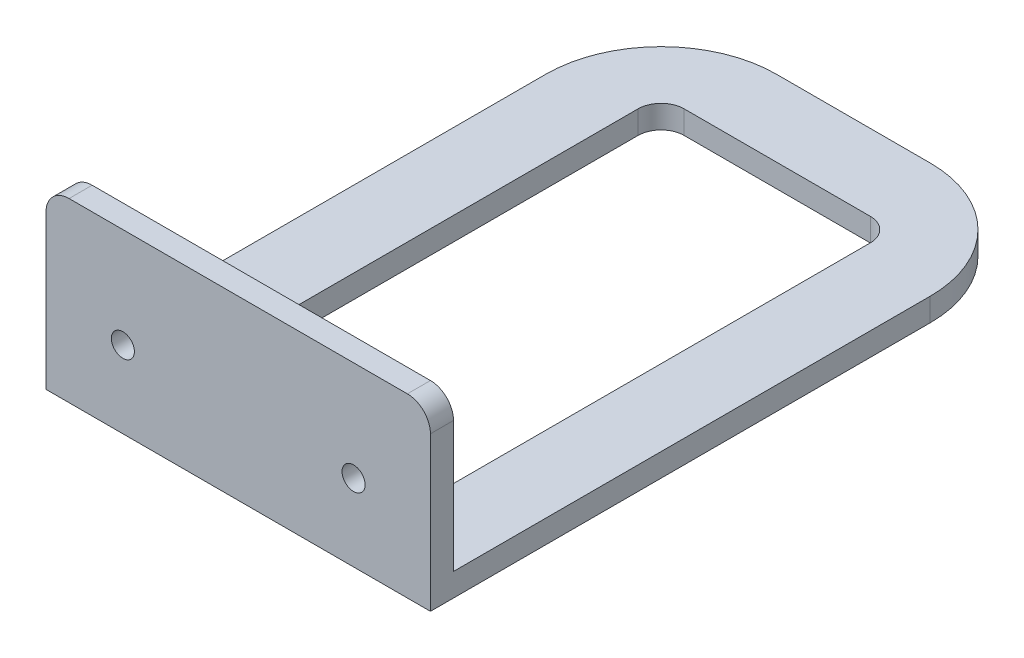
from build123d import *

# Parameters (mm, degrees)
SKETCH1_W           = 50
SKETCH1_H           = 80
BOSS_EXTRUDE1_DEPTH = 3
SKETCH2_W           = 50
SKETCH2_H           = 3
BOSS_EXTRUDE2_DEPTH = 20
FILLET1_R           = 3
FILLET2_R           = 15
CUT_EXTRUDE1_DEPTH  = 4
CUT_EXTRUDE2_DEPTH  = 81


with BuildPart() as part:
    # Sketch1 → Boss-Extrude1 (new body)
    with BuildSketch(Plane(origin=(0, 0, 0), x_dir=(1, 0, 0), z_dir=(0, 1, 0))):
        Rectangle(SKETCH1_W, SKETCH1_H)
    extrude(amount=BOSS_EXTRUDE1_DEPTH)

    # Sketch2 → Boss-Extrude2 (add)
    with BuildSketch(Plane(origin=(0, 3, 0), x_dir=(1, 0, 0), z_dir=(0, 1, 0))):
        with Locations((0, -38.5)):
            Rectangle(SKETCH2_W, SKETCH2_H)
    extrude(amount=BOSS_EXTRUDE2_DEPTH)

    # Fillet1
    fillet1_edges = [part.edges().sort_by_distance(p)[0] for p in [
        (-25, 23, 38.5),
        (25, 23, 38.5),
    ]]
    fillet(fillet1_edges, radius=FILLET1_R)

    # Fillet2
    fillet2_edges = [part.edges().sort_by_distance(p)[0] for p in [
        (-25, 1.5, -40),
        (25, 1.5, -40),
    ]]
    fillet(fillet2_edges, radius=FILLET2_R)

    # Sketch3 → Cut-Extrude1 (cut, through all)
    with BuildSketch(Plane(origin=(0, 3, 0), x_dir=(1, 0, 0), z_dir=(0, 1, 0))):
        with BuildLine():
            Line((-12.1, 30.1), (12.1, 30.1))
            ThreePointArc((12.1, 30.1), (14.221320344, 29.221320344), (15.1, 27.1))
            Line((15.1, 27.1), (15.1, -27.1))
            ThreePointArc((15.1, -27.1), (14.221320344, -29.221320344), (12.1, -30.1))
            Line((12.1, -30.1), (-12.1, -30.1))
            ThreePointArc((-12.1, -30.1), (-14.221320344, -29.221320344), (-15.1, -27.1))
            Line((-15.1, -27.1), (-15.1, 27.1))
            ThreePointArc((-15.1, 27.1), (-14.221320344, 29.221320344), (-12.1, 30.1))
        make_face()
    extrude(amount=-CUT_EXTRUDE1_DEPTH, mode=Mode.SUBTRACT)

    # Sketch4 → Cut-Extrude2 (cut, through all)
    with BuildSketch(Plane.XY.offset(40)):
        with BuildLine():
            Line((-15, 8.5), (-15, 10))
            Line((-15, 10), (-13.5, 10))
            ThreePointArc((-13.5, 10), (-16.060660172, 11.060660172), (-15, 8.5))
        make_face()
        with BuildLine():
            Line((-13.5, 10), (-15, 10))
            Line((-15, 10), (-15, 8.5))
            ThreePointArc((-15, 8.5), (-13.939339828, 8.939339828), (-13.5, 10))
        make_face()
        with BuildLine():
            ThreePointArc((16.5, 10), (15, 11.5), (13.5, 10))
            Line((13.5, 10), (15, 10))
            Line((15, 10), (15, 8.5))
            ThreePointArc((15, 8.5), (16.060660172, 8.939339828), (16.5, 10))
        make_face()
        with BuildLine():
            Line((15, 10), (13.5, 10))
            ThreePointArc((13.5, 10), (13.939339828, 8.939339828), (15, 8.5))
            Line((15, 8.5), (15, 10))
        make_face()
    extrude(amount=-CUT_EXTRUDE2_DEPTH, mode=Mode.SUBTRACT)


solid = part.part
